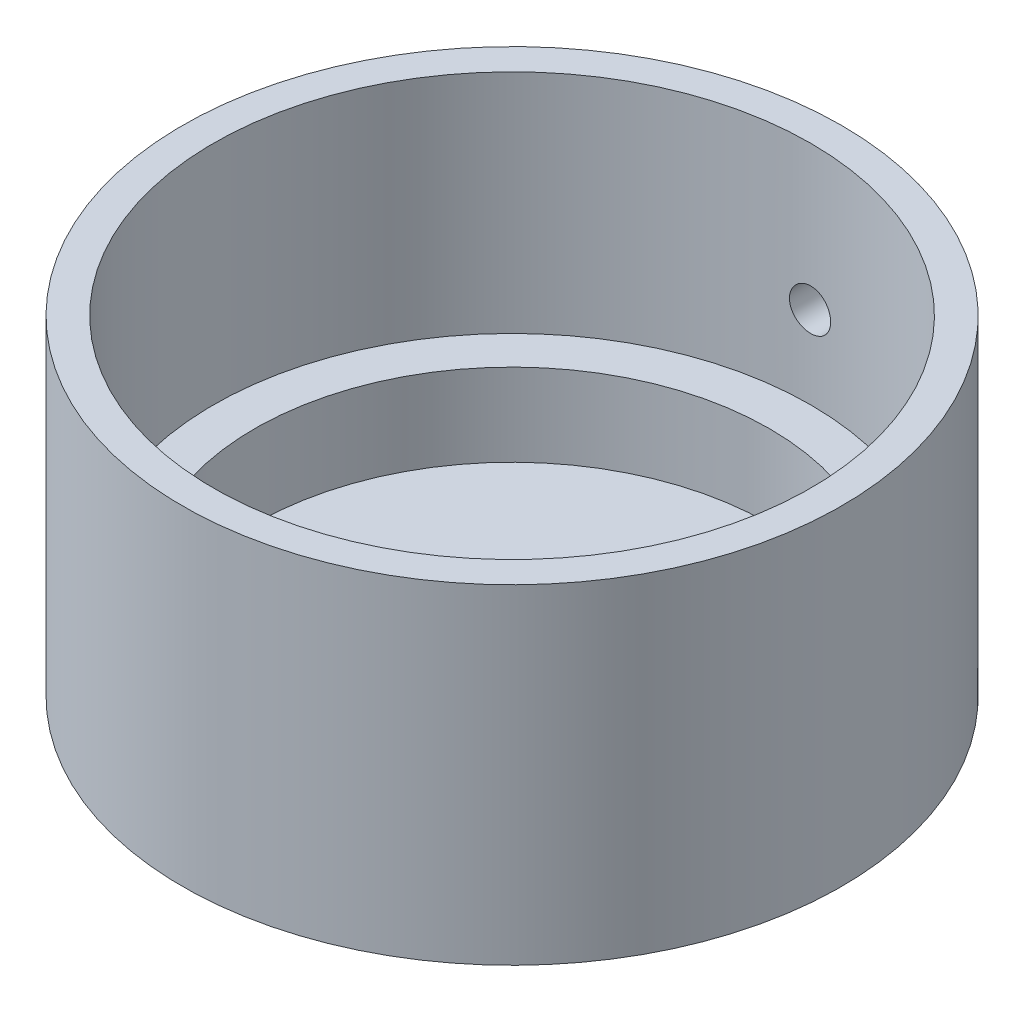
from build123d import *

# Parameters (mm, degrees)
CUT_EXTRUDE_1_REACH = 18
SKETCH_2_R          = 1


with BuildPart() as part:
    # Эскиз1 → Повернуть1 (revolve)
    with BuildSketch(Plane.XY):
        Polygon((0, 0), (12.5, 0), (12.5, 4), (14.5, 4), (14.5, 15), (16, 15), (16, -1), (0, -1), align=None)
    revolve(axis=Axis((0, -1, 0), (0, 1, 0)))

    # Эскиз2 → Вырез-Вытянуть1 (cut, up to next)
    with BuildSketch(Plane.XY, mode=Mode.PRIVATE) as cut_extrude_1_sk1:
        with Locations((0, 8)):
            Circle(SKETCH_2_R)
    cut_extrude_1_tool1 = extrude(cut_extrude_1_sk1.sketch, amount=-CUT_EXTRUDE_1_REACH, mode=Mode.PRIVATE) & part.part
    add(cut_extrude_1_tool1.solids().sort_by_distance((0, 8, 0))[0], mode=Mode.SUBTRACT)


solid = part.part
